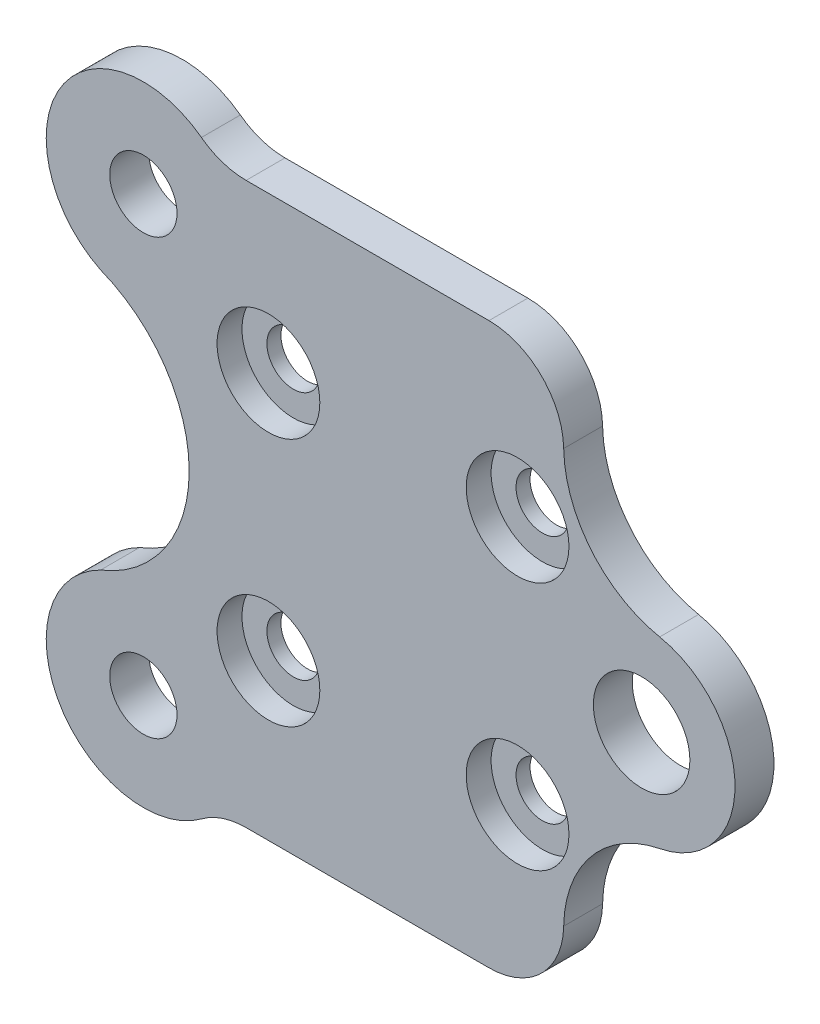
from build123d import *

# Parameters (mm, degrees)
MODEL_R             = 2.7
MODEL_R_2           = 3.875
MODEL_R_3           = 2.125
BOSS_EXTRUDE1_DEPTH = 3.125
MODEL_3_R           = 4.125
MODEL_3_R_2         = 2.125
CUT_EXTRUDE1_DEPTH  = 2
FILLET1_R           = 6
FILLET2_R           = 6


with BuildPart() as part:
    # Model → Boss-Extrude1 (new body)
    with BuildSketch(Plane.XY):
        with BuildLine():
            Line((85.751165458, 39.930508181), (57.940219492, 39.930508181))
            ThreePointArc((57.940219492, 39.930508181), (45.846452894, 39.648352972), (48.573590158, 27.862703884))
            ThreePointArc((48.573590158, 27.862703884), (55.686625956, 17.430508181), (48.573590158, 6.998312478))
            ThreePointArc((48.573590158, 6.998312478), (45.846452894, -4.78733661), (57.940219492, -5.069491819))
            Line((57.940219492, -5.069491819), (85.751165458, -5.069491819))
            Line((85.751165458, -5.069491819), (85.751165458, 0.769903947))
            ThreePointArc((85.751165458, 0.769903947), (87.9590359, 6.783913161), (93.457436342, 10.071859524))
            ThreePointArc((93.457436342, 10.071859524), (99.50819863, 17.430508181), (93.457436342, 24.789156838))
            ThreePointArc((93.457436342, 24.789156838), (87.9590359, 28.077103201), (85.751165458, 34.091112415))
            Line((85.751165458, 34.091112415), (85.751165458, 39.930508181))
        make_face()
        with Locations((52.008207521, -0.004787091)):
            Circle(MODEL_R, mode=Mode.SUBTRACT)
        with Locations((52.008207521, 34.865803453)):
            Circle(MODEL_R, mode=Mode.SUBTRACT)
        with Locations((92.00819863, 17.430508181)):
            Circle(MODEL_R_2, mode=Mode.SUBTRACT)
        with Locations((62.05010788, 7.430508181)):
            Circle(MODEL_R_3, mode=Mode.SUBTRACT)
        with Locations((82.050054867, 7.430508181)):
            Circle(MODEL_R_3, mode=Mode.SUBTRACT)
        with Locations((62.05010788, 27.430508181)):
            Circle(MODEL_R_3, mode=Mode.SUBTRACT)
        with Locations((82.050054867, 27.430508181)):
            Circle(MODEL_R_3, mode=Mode.SUBTRACT)
    extrude(amount=-BOSS_EXTRUDE1_DEPTH)

    # Model_3 → Cut-Extrude1 (cut)
    # profile 1 of 4: a face of its own
    with BuildSketch(Plane.XY):
        with Locations((82.050054867, 27.430508181)):
            Circle(MODEL_3_R)
    # profile 2 of 4: a face of its own
    with BuildSketch(Plane.XY):
        with Locations((62.05010788, 27.430508181)):
            Circle(MODEL_3_R)
        with Locations((62.05010788, 27.430508181)):
            Circle(MODEL_3_R_2, mode=Mode.SUBTRACT)
    # profile 3 of 4: a face of its own
    with BuildSketch(Plane.XY):
        with Locations((62.05010788, 7.430508181)):
            Circle(MODEL_3_R)
        with Locations((62.05010788, 7.430508181)):
            Circle(MODEL_3_R_2, mode=Mode.SUBTRACT)
    # profile 4 of 4: a face of its own
    with BuildSketch(Plane.XY):
        with Locations((82.050054867, 7.430508181)):
            Circle(MODEL_3_R)
        with Locations((82.050054867, 7.430508181)):
            Circle(MODEL_3_R_2, mode=Mode.SUBTRACT)
    extrude(amount=-CUT_EXTRUDE1_DEPTH, mode=Mode.SUBTRACT)

    # Fillet1
    fillet1_edges = [part.edges().sort_by_distance(p)[0] for p in [
        (85.751165458, -5.069491819, -1.5625),
        (85.751165458, 39.930508181, -1.5625),
    ]]
    fillet(fillet1_edges, radius=FILLET1_R)

    # Fillet2
    fillet2_edges = [part.edges().sort_by_distance(p)[0] for p in [
        (57.940219492, 39.930508181, -1.5625),
        (57.940219492, -5.069491819, -1.5625),
    ]]
    fillet(fillet2_edges, radius=FILLET2_R)


solid = part.part
